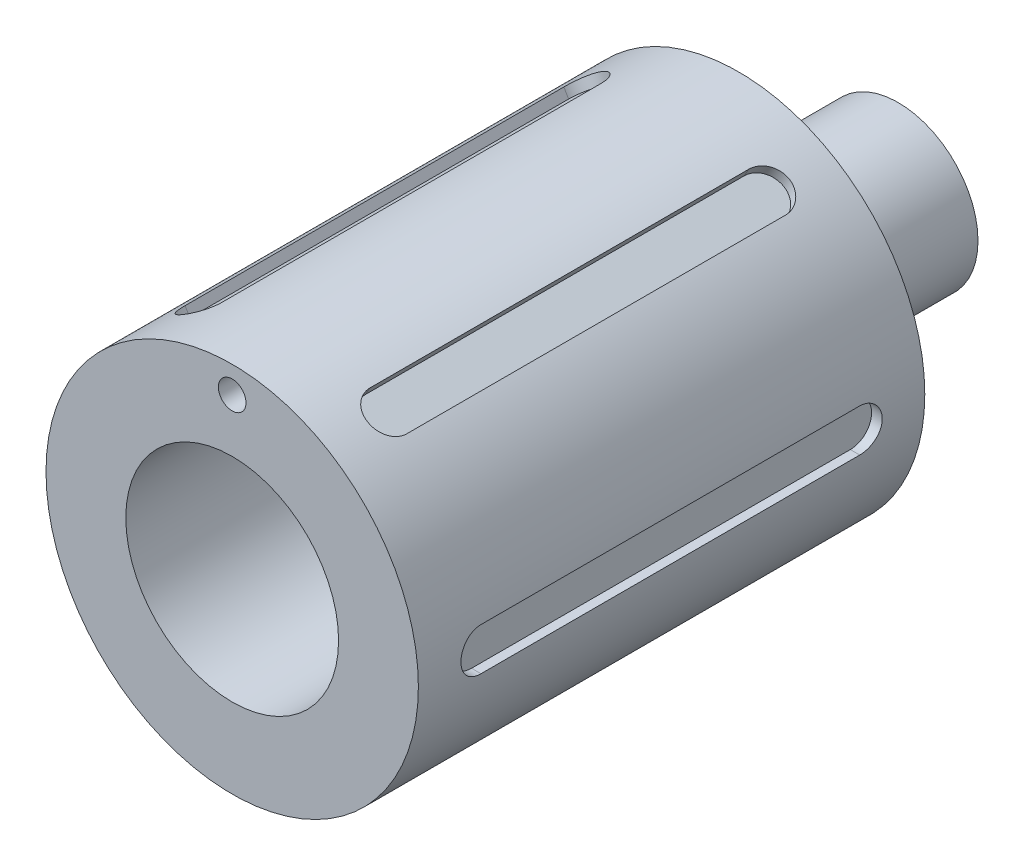
from build123d import *

# Parameters (mm, degrees)
F_1_4_1_DIAMETER_HOLE1_D        = 25.4
F_1_4_1_DIAMETER_HOLE1_DEPTH    = 57.15
F_1_4_0_13_DIAMETER_HOLE1_D     = 3.302
F_1_4_0_13_DIAMETER_HOLE1_DEPTH = 15.875
F_1_4_0_13_DIAMETER_HOLE1_TIP   = 0.992020882
CUT_EXTRUDE2_DEPTH              = 1.27
CIRPATTERN2_COUNT               = 6


with BuildPart() as part:
    # Sketch1 → Revolve1 (revolve)
    with BuildSketch(Plane(origin=(0, 0, 0), x_dir=(0, 0, -1), z_dir=(1, 0, 0))):
        Polygon((0, 0), (-79.502, 0), (-79.502, 22.225), (-19.05, 22.225), (-19.05, 9.525), (0, 9.525), align=None)
    revolve(axis=Axis((0, 0, 0), (0, 0, -1)))

    # 1_4 _1_ Diameter Hole1
    with Locations(Plane.XY.offset(79.502)):
        with Locations((0, 0)):
            Hole(F_1_4_1_DIAMETER_HOLE1_D / 2, depth=F_1_4_1_DIAMETER_HOLE1_DEPTH)

    # 1_4 _0.13_ Diameter Hole1
    with Locations(Plane.XY.offset(79.502)):
        with Locations((0, 19.05)):
            Hole(F_1_4_0_13_DIAMETER_HOLE1_D / 2, depth=F_1_4_0_13_DIAMETER_HOLE1_DEPTH)
            with Locations((0, 0, -(F_1_4_0_13_DIAMETER_HOLE1_DEPTH + F_1_4_0_13_DIAMETER_HOLE1_TIP / 2))):  # 118° drill point
                Cone(0, F_1_4_0_13_DIAMETER_HOLE1_D / 2, F_1_4_0_13_DIAMETER_HOLE1_TIP, mode=Mode.SUBTRACT)

    # Sketch10 → Cut-Extrude2 (cut)
    with BuildSketch(Plane(origin=(22.225, 0, 0), x_dir=(0, 0, -1), z_dir=(1, 0, 0))):
        with BuildLine():
            Line((-71.882, 2.54), (-26.67, 2.54))
            ThreePointArc((-26.67, 2.54), (-24.13, 0), (-26.67, -2.54))
            Line((-26.67, -2.54), (-71.882, -2.54))
            ThreePointArc((-71.882, -2.54), (-74.422, 0), (-71.882, 2.54))
        make_face()
    cut_extrude2 = extrude(amount=-CUT_EXTRUDE2_DEPTH, mode=Mode.SUBTRACT)

    # CirPattern2: Cut-Extrude2 ×6 about axis
    cirpattern2_axis = Axis((0, 0, 0), (0, 0, 1))
    for i in range(1, CIRPATTERN2_COUNT):
        add(cut_extrude2.rotate(cirpattern2_axis, i * 360 / CIRPATTERN2_COUNT), mode=Mode.SUBTRACT)


solid = part.part
